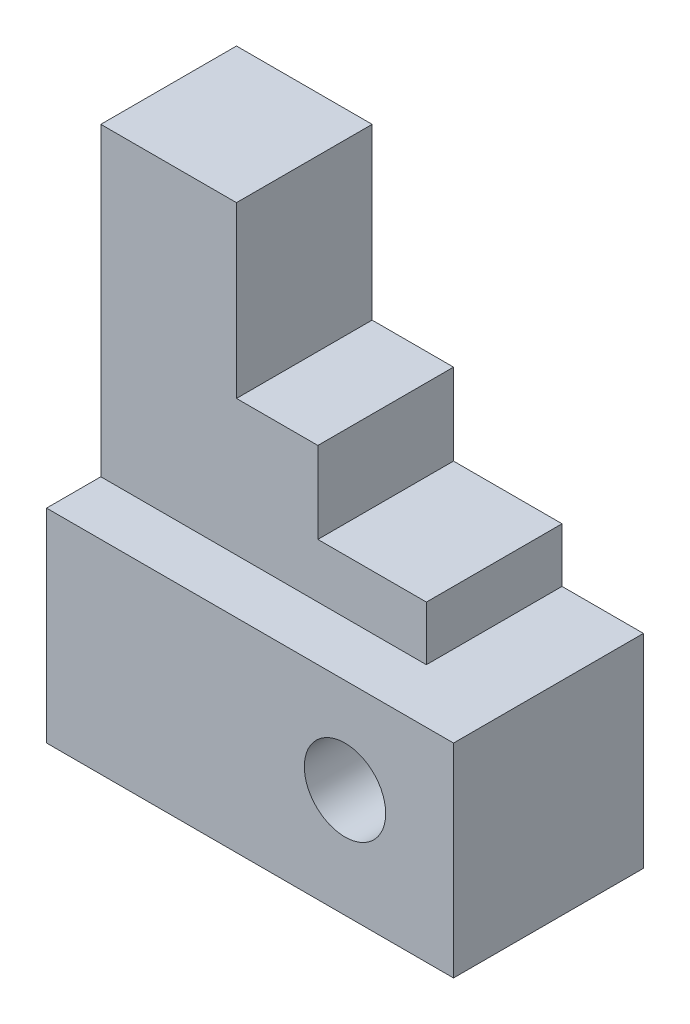
from build123d import *

# Parameters (mm, degrees)
SKETCH2_W           = 60
SKETCH2_H           = 30
SKETCH2_R           = 6
BOSS_EXTRUDE2_DEPTH = 28
BOSS_EXTRUDE3_DEPTH = 20


with BuildPart() as part:
    # Sketch2 → Boss-Extrude2 (new body)
    with BuildSketch(Plane.XY):
        with Locations((30, 15)):
            Rectangle(SKETCH2_W, SKETCH2_H)
        with Locations((44, 16)):
            Circle(SKETCH2_R, mode=Mode.SUBTRACT)
    extrude(amount=BOSS_EXTRUDE2_DEPTH)

    # Sketch2_5 → Boss-Extrude3 (add)
    with BuildSketch(Plane.XY):
        Polygon((0, 75), (0, 30), (48, 30), (48, 38), (32, 38), (32, 50), (20, 50), (20, 75), align=None)
    extrude(amount=BOSS_EXTRUDE3_DEPTH)


solid = part.part
